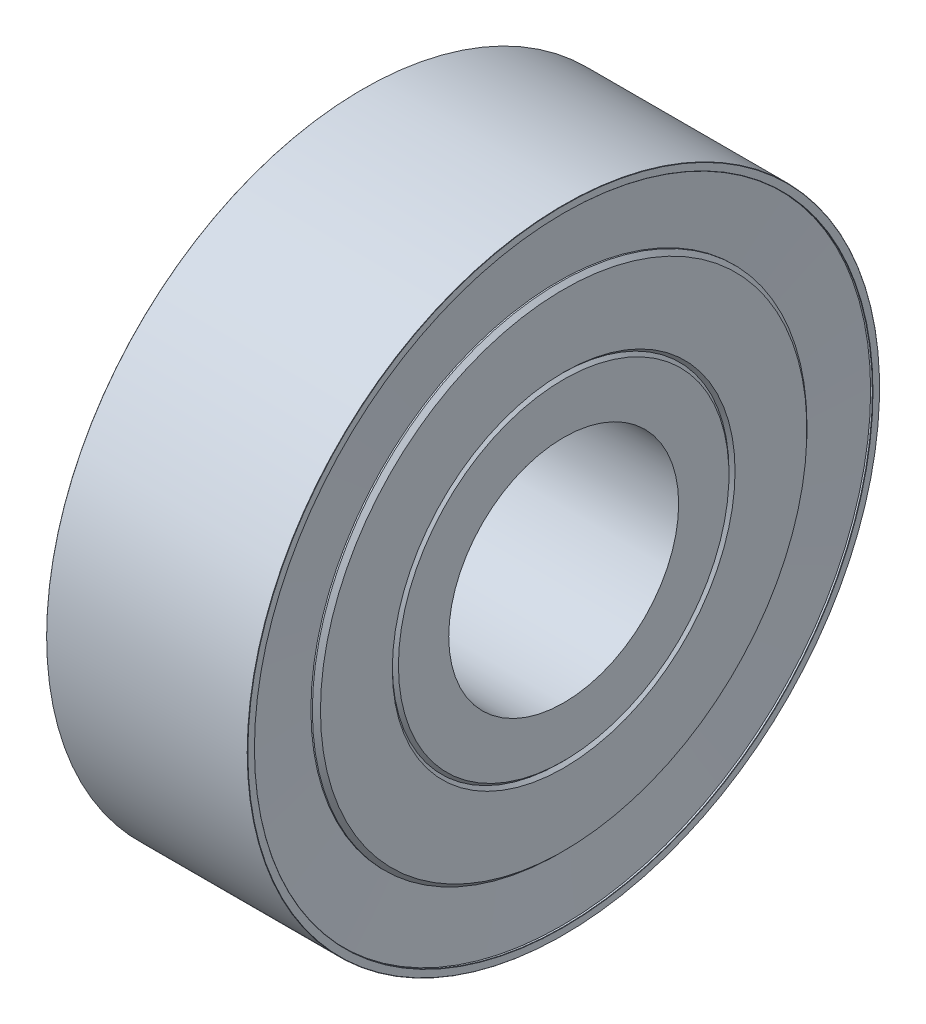
from build123d import *


with BuildPart() as part:
    # Sketch1 → Revolve1 (revolve)
    with BuildSketch(Plane.XY):
        Polygon((-3.5, 4), (3.5, 4), (3.5, 5.75), (3.393933983, 5.856066017), (3.5, 5.962132034), (3.5, 8.462132034), (3.358578644, 8.603553391), (3.308578644, 8.603553391), (3.429289322, 10.75), (3.49, 10.75), (3.5, 10.76), (3.5, 10.99), (3.489185937, 11), (-3.489185937, 11), (-3.5, 10.99), (-3.5, 10.76), (-3.49, 10.75), (-3.429289322, 10.75), (-3.308578644, 8.603553391), (-3.358578644, 8.603553391), (-3.5, 8.462132034), (-3.5, 5.962132034), (-3.393933983, 5.856066017), (-3.5, 5.75), align=None)
    revolve(axis=Axis((-0.54284752, 0, 0), (1, 0, 0)))


solid = part.part
